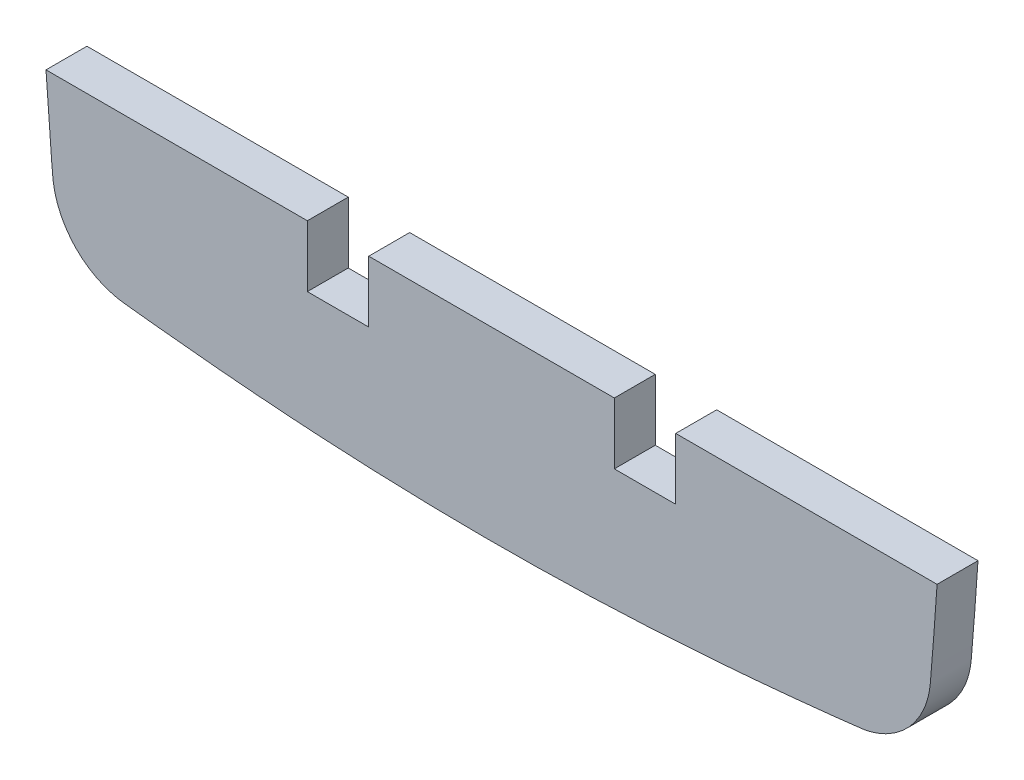
from build123d import *

# Parameters (mm, degrees)
BOSS_EXTRUDE1_DEPTH = 5.08


with BuildPart() as part:
    # Sketch1 → Boss-Extrude1 (new body)
    with BuildSketch(Plane.XY):
        with BuildLine():
            Line((40.64, -38.1), (8.205339518, -38.1))
            add(Edge.make_bspline(
                [(118.794680008, -38.1), (118.759672897, -38.625347071), (118.724258234, -39.146510327), (118.688475704, -39.663489231), (118.535530504, -41.873211203), (118.375831529, -44.006639059), (118.212122411, -46.064412329), (118.130267851, -47.093298963), (118.047404681, -48.103276333), (117.963840874, -49.094448309), (117.92205897, -49.590034297), (117.844217868, -50.086214445), (117.730734608, -50.575369303), (117.673992979, -50.819946732), (117.608368499, -51.062776245), (117.533960636, -51.302972114), (117.496756704, -51.423070048), (117.457357006, -51.542510316), (117.394983163, -51.720524779), (117.373646171, -51.779671989), (117.340824578, -51.868086867), (117.32974803, -51.897507507), (117.312929493, -51.941559571), (117.307289361, -51.956230444), (117.298778274, -51.978216729), (117.295932763, -51.985542154), (117.290224785, -52.000186278), (117.288098735, -52.00562855), (117.284491375, -52.014820291), (116.8227494, -53.191363178), (116.129581452, -54.295586139), (114.406454226, -56.148659315), (113.375780722, -56.896057665), (112.287367861, -57.419878779), (111.74316143, -57.681789336), (111.184363838, -57.888235292), (110.623875123, -58.04230616), (110.343630765, -58.119341593), (110.062953092, -58.183281641), (109.783392063, -58.234502898), (109.643611549, -58.260113527), (109.50410955, -58.282544359), (109.226042359, -58.321139392), (109.087616268, -58.336468265), (108.949267124, -58.352392298), (107.842473971, -58.479784559), (106.744921168, -58.602532211), (105.656576053, -58.720618238), (103.479885823, -58.95679029), (101.340020244, -59.174298512), (99.236797061, -59.37322428), (98.18518547, -59.472687164), (97.142730668, -59.567504544), (96.109441385, -59.657730099), (95.592796744, -59.702842876), (95.078444667, -59.746808831), (94.566388564, -59.789637618), (94.310360512, -59.811052012), (94.054906454, -59.832182125), (93.800026821, -59.853029236), (93.672587004, -59.863452791), (93.545290793, -59.873805596), (93.354561966, -59.889228924), (93.291021606, -59.894352386), (93.195764948, -59.902011142), (93.164021709, -59.904559654), (93.116420323, -59.908375816), (93.100555439, -59.90964677), (93.076761482, -59.911551548), (93.068830724, -59.912186199), (93.052970332, -59.913454951), (93.046286525, -59.913989465), (93.037111623, -59.914722878), (88.339562122, -60.290230564), (83.741773174, -60.576255289), (79.245800454, -60.774742484), (76.997814095, -60.873986082), (74.775333496, -60.951451187), (72.57870331, -61.007908028), (71.480388217, -61.036136448), (70.388536383, -61.059129773), (69.303190357, -61.077027476), (68.760517344, -61.085976327), (68.219470747, -61.093651328), (67.680055664, -61.100070235), (67.410348122, -61.103279688), (67.141048456, -61.106175121), (66.603266122, -61.111342424), (66.336069703, -61.113604878), (66.066709899, -61.115576633), (63.911831461, -61.131350671), (61.727879233, -61.127404428), (57.317129254, -61.077451929), (55.088686315, -61.031526552), (50.586325041, -60.895868863), (48.31241048, -60.80609014), (46.016090198, -60.693915052), (44.867930056, -60.637827508), (43.714168745, -60.576144299), (42.55484899, -60.508824213), (41.975189112, -60.47516417), (41.39413964, -60.44009504), (40.811706002, -60.403612474), (40.520489183, -60.385371191), (40.228926393, -60.366776434), (39.937017926, -60.347828404), (39.791063692, -60.338354389), (39.645023033, -60.328792067), (39.425832444, -60.314316199), (39.352747315, -60.309468845), (39.243087225, -60.302164728), (39.206528462, -60.299724507), (39.15168222, -60.296055906), (39.13339879, -60.294831661), (39.09682923, -60.292380414), (39.076484845, -60.291015157), (39.060255621, -60.289925031), (34.905574211, -60.010852755), (30.611335524, -59.655570775), (26.17878384, -59.22053735), (23.962507998, -59.003020637), (21.711549809, -58.765697989), (19.425632206, -58.508782333), (19.139892506, -58.476667876), (18.853606418, -58.444247675), (18.566773273, -58.411522489), (18.423356701, -58.395159896), (18.279803363, -58.378721058), (17.992422986, -58.345691097), (17.848731161, -58.330193769), (17.704473886, -58.311232443), (17.127444785, -58.235387139), (16.542036633, -58.105626515), (15.382178109, -57.731878979), (14.807725641, -57.487485482), (14.253300243, -57.183617922), (13.976087545, -57.031684142), (13.703893331, -56.865202294), (13.438604879, -56.684941122), (13.305960653, -56.594810535), (13.175043558, -56.50123546), (12.981618731, -56.355853353), (12.917635635, -56.30655609), (12.822444167, -56.231373953), (12.79084421, -56.206107202), (12.743645773, -56.167900354), (12.727946544, -56.155113618), (12.70444879, -56.135857126), (12.69662472, -56.129425565), (12.680993729, -56.116537028), (12.67169213, -56.10884003), (12.665388521, -56.103610395), (12.261957551, -55.768913788), (11.879972032, -55.39849829), (11.175902321, -54.593106183), (10.853247639, -54.158677458), (10.278128772, -53.240852172), (10.025711712, -52.757455304), (9.603115192, -51.757708214), (9.432525975, -51.241341463), (9.173802937, -50.192809561), (9.085669411, -49.660642373), (8.992709548, -48.599307174), (8.949925608, -48.064745788), (8.905787207, -47.525534513), (8.817510407, -46.447111963), (8.730527968, -45.351072984), (8.645169546, -44.237350837), (8.492706337, -42.248072573), (8.345405571, -40.202363138), (8.205339518, -38.1)],
                knots=[0.33876349, 0.33876349, 0.33876349, 0.33876349, 0.339285714, 0.339285714, 0.339285714, 0.34375, 0.34375, 0.34375, 0.348214286, 0.348214286, 0.348214286, 0.352678571, 0.352678571, 0.352678571, 0.357142857, 0.357142857, 0.357142857, 0.361607143, 0.361607143, 0.366071429, 0.366071429, 0.370535714, 0.370535714, 0.375, 0.375, 0.379464286, 0.379464286, 0.383928571, 0.383928571, 0.383928571, 0.388392857, 0.388392857, 0.392857143, 0.392857143, 0.392857143, 0.397321429, 0.397321429, 0.397321429, 0.401785714, 0.401785714, 0.401785714, 0.40625, 0.40625, 0.410714286, 0.410714286, 0.410714286, 0.415178571, 0.415178571, 0.415178571, 0.419642857, 0.419642857, 0.419642857, 0.424107143, 0.424107143, 0.424107143, 0.428571429, 0.428571429, 0.428571429, 0.433035714, 0.433035714, 0.433035714, 0.4375, 0.4375, 0.441964286, 0.441964286, 0.446428571, 0.446428571, 0.450892857, 0.450892857, 0.455357143, 0.455357143, 0.459821429, 0.459821429, 0.459821429, 0.464285714, 0.464285714, 0.464285714, 0.46875, 0.46875, 0.46875, 0.473214286, 0.473214286, 0.473214286, 0.477678571, 0.477678571, 0.477678571, 0.482142857, 0.482142857, 0.486607143, 0.486607143, 0.486607143, 0.491071429, 0.491071429, 0.495535714, 0.495535714, 0.5, 0.5, 0.5, 0.504464286, 0.504464286, 0.504464286, 0.508928571, 0.508928571, 0.508928571, 0.513392857, 0.513392857, 0.513392857, 0.517857143, 0.517857143, 0.522321429, 0.522321429, 0.526785714, 0.526785714, 0.53125, 0.53125, 0.535714286, 0.535714286, 0.535714286, 0.540178571, 0.540178571, 0.540178571, 0.544642857, 0.544642857, 0.544642857, 0.549107143, 0.549107143, 0.549107143, 0.553571429, 0.553571429, 0.558035714, 0.558035714, 0.558035714, 0.5625, 0.5625, 0.566964286, 0.566964286, 0.566964286, 0.571428571, 0.571428571, 0.571428571, 0.575892857, 0.575892857, 0.580357143, 0.580357143, 0.584821429, 0.584821429, 0.589285714, 0.589285714, 0.59375, 0.59375, 0.598214286, 0.598214286, 0.598214286, 0.602678571, 0.602678571, 0.607142857, 0.607142857, 0.611607143, 0.611607143, 0.616071429, 0.616071429, 0.620535714, 0.620535714, 0.625, 0.625, 0.625, 0.629464286, 0.629464286, 0.629464286, 0.633451235, 0.633451235, 0.633451235, 0.633451235], degree=3))
            Line((118.794680008, -38.1), (86.36, -38.1))
            Line((86.36, -38.1), (86.36, -45.72))
            Line((86.36, -45.72), (78.74, -45.72))
            Line((78.74, -45.72), (78.74, -38.1))
            Line((78.74, -38.1), (48.26, -38.1))
            Line((48.26, -38.1), (48.26, -45.72))
            Line((48.26, -45.72), (40.64, -45.72))
            Line((40.64, -45.72), (40.64, -38.1))
        make_face()
    extrude(amount=BOSS_EXTRUDE1_DEPTH)


solid = part.part
